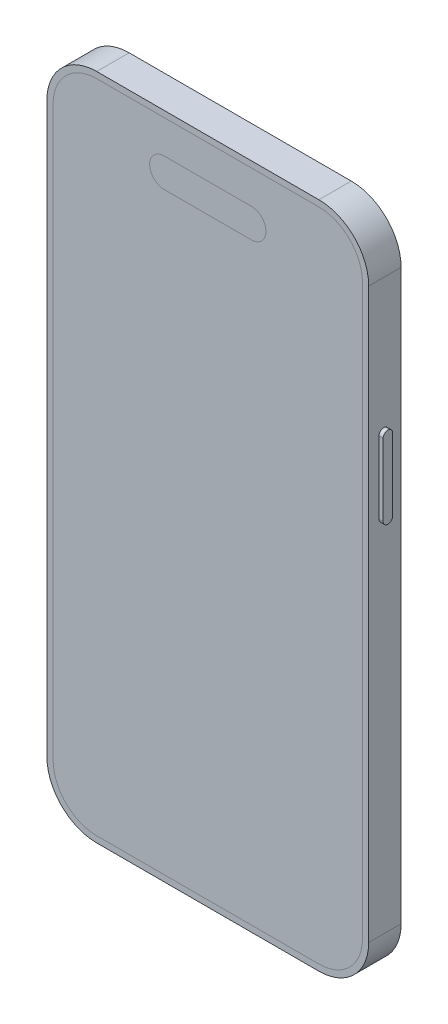
from build123d import *

# Parameters (mm, degrees)
EXTRUDE_1_DEPTH  = 7.8
EXTRUDE_3_DEPTH  = 1.2
SKETCH_9_4_R     = 8.191420507
EXTRUDE_4_DEPTH  = 4
SKETCH_9_5_R     = 1.750016101
EXTRUDE_5_DEPTH  = 3
EXTRUDE_7_DEPTH  = 1
EXTRUDE_8_DEPTH  = 1
EXTRUDE_9_DEPTH  = 1
SKETCH_11_R      = 1.061990405
EXTRUDE_10_DEPTH = 0.08


with BuildPart() as part:
    # 草图1 → 凸台-拉伸1 (new body)
    with BuildSketch(Plane.XY):
        with BuildLine():
            Line((26.75, -80.45), (-26.75, -80.45))
            ThreePointArc((-26.75, -80.45), (-35.235281374, -76.935281374), (-38.75, -68.45))
            Line((-38.75, -68.45), (-38.75, 68.45))
            ThreePointArc((-38.75, 68.45), (-35.235281374, 76.935281374), (-26.75, 80.45))
            Line((-26.75, 80.45), (26.75, 80.45))
            ThreePointArc((26.75, 80.45), (35.235281374, 76.935281374), (38.75, 68.45))
            Line((38.75, 68.45), (38.75, -68.45))
            ThreePointArc((38.75, -68.45), (35.235281374, -76.935281374), (26.75, -80.45))
        make_face()
    extrude(amount=EXTRUDE_1_DEPTH)

    # 草图9 → 凸台-拉伸3 (add)
    with BuildSketch(Plane(origin=(0, 0, 0), x_dir=(-1, 0, 0), z_dir=(0, 0, -1))):
        with BuildLine():
            Line((-27.75, 75.45), (-5.75, 75.45))
            ThreePointArc((-5.75, 75.45), (-0.093145751, 73.106854249), (2.25, 67.45))
            Line((2.25, 67.45), (2.25, 45.45))
            ThreePointArc((2.25, 45.45), (-0.093145751, 39.793145751), (-5.75, 37.45))
            Line((-5.75, 37.45), (-27.75, 37.45))
            ThreePointArc((-27.75, 37.45), (-33.406854249, 39.793145751), (-35.75, 45.45))
            Line((-35.75, 45.45), (-35.75, 67.45))
            ThreePointArc((-35.75, 67.45), (-33.406854249, 73.106854249), (-27.75, 75.45))
        make_face()
    extrude(amount=EXTRUDE_3_DEPTH)

    # 草图9<4> → 凸台-拉伸4 (add)
    with BuildSketch(Plane(origin=(0, 0, 0), x_dir=(-1, 0, 0), z_dir=(0, 0, -1))):
        with Locations((-25.75, 65.45)):
            Circle(SKETCH_9_4_R)
        with Locations((-7.75, 57.360656258)):
            Circle(SKETCH_9_4_R)
        with Locations((-25.75, 47.45)):
            Circle(SKETCH_9_4_R)
    extrude(amount=EXTRUDE_4_DEPTH)

    # 草图9<5> → 凸台-拉伸5 (add)
    with BuildSketch(Plane(origin=(0, 0, 0), x_dir=(-1, 0, 0), z_dir=(0, 0, -1))):
        with Locations((-9.360421126, 69.360656258)):
            Circle(SKETCH_9_5_R)
    extrude(amount=EXTRUDE_5_DEPTH)

    # 草图12 → 凸台-拉伸7 (add)
    with BuildSketch(Plane.ZY.offset(38.75)):
        with BuildLine():
            Line((4.686466023, 51.699871834), (4.686466023, 46.158543385))
            ThreePointArc((4.686466023, 46.158543385), (3.550247732, 45.022325093), (2.41402944, 46.158543385))
            Line((2.41402944, 46.158543385), (2.41402944, 51.699871834))
            ThreePointArc((2.41402944, 51.699871834), (3.550247732, 52.836090125), (4.686466023, 51.699871834))
        make_face()
    extrude(amount=EXTRUDE_7_DEPTH)

    # 草图12<3> → 凸台-拉伸8 (add)
    with BuildSketch(Plane.ZY.offset(38.75)):
        with BuildLine():
            Line((4.686466023, 51.699871834), (4.686466023, 46.158543385))
            ThreePointArc((4.686466023, 46.158543385), (3.550247732, 45.022325093), (2.41402944, 46.158543385))
            Line((2.41402944, 46.158543385), (2.41402944, 51.699871834))
            ThreePointArc((2.41402944, 51.699871834), (3.550247732, 52.836090125), (4.686466023, 51.699871834))
        make_face()
        with BuildLine():
            Line((2.585183967, 27.92697733), (2.585183967, 39.027618957))
            ThreePointArc((2.585183967, 39.027618957), (3.550247732, 39.992682722), (4.515311496, 39.027618957))
            Line((4.515311496, 39.027618957), (4.515311496, 27.92697733))
            ThreePointArc((4.515311496, 27.92697733), (3.550247732, 26.961913565), (2.585183967, 27.92697733))
        make_face()
        with BuildLine():
            Line((2.34585079, 8.760131584), (2.34585079, 22.388503734))
            ThreePointArc((2.34585079, 22.388503734), (3.550247732, 23.592900676), (4.754644674, 22.388503734))
            Line((4.754644674, 22.388503734), (4.754644674, 8.760131584))
            ThreePointArc((4.754644674, 8.760131584), (3.550247732, 7.555734642), (2.34585079, 8.760131584))
        make_face()
    extrude(amount=EXTRUDE_8_DEPTH)

    # 草图13 → 凸台-拉伸9 (add)
    with BuildSketch(Plane(origin=(38.75, 0, 0), x_dir=(0, 0, -1), z_dir=(1, 0, 0))):
        with BuildLine():
            Line((-3.041514771, 35.957715301), (-3.041514771, 18.606690775))
            ThreePointArc((-3.041514771, 18.606690775), (-4.183029543, 17.465176003), (-5.324544314, 18.606690775))
            Line((-5.324544314, 18.606690775), (-5.324544314, 35.957715301))
            ThreePointArc((-5.324544314, 35.957715301), (-4.183029543, 37.099230072), (-3.041514771, 35.957715301))
        make_face()
    extrude(amount=EXTRUDE_9_DEPTH)

    # 草图11 → 凸台-拉伸10 (add)
    with BuildSketch(Plane(origin=(0, 0, -1.2), x_dir=(-1, 0, 0), z_dir=(0, 0, -1))):
        with Locations((-9.68745595, 42.936842594)):
            Circle(SKETCH_11_R)
    extrude(amount=EXTRUDE_10_DEPTH)


solid = part.part
